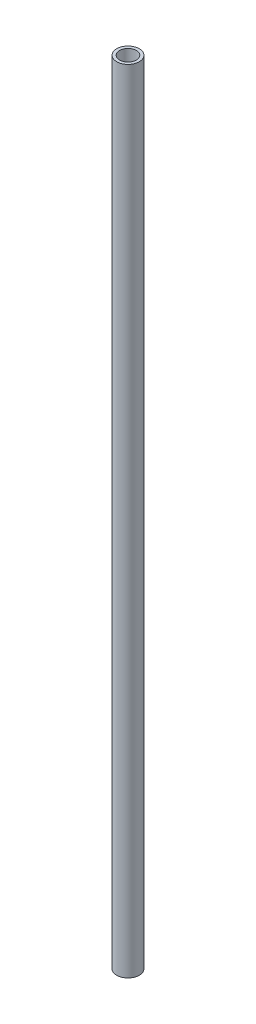
from build123d import *

# Parameters (mm, degrees)
SKETCH1_R           = 10.668
SKETCH1_R_2         = 7.8994
BOSS_EXTRUDE1_DEPTH = 748


with BuildPart() as part:
    # Sketch1 → Boss-Extrude1 (new body)
    with BuildSketch(Plane(origin=(0, 0, 0), x_dir=(1, 0, 0), z_dir=(0, 1, 0))):
        Circle(SKETCH1_R)
        Circle(SKETCH1_R_2, mode=Mode.SUBTRACT)
    extrude(amount=BOSS_EXTRUDE1_DEPTH)


solid = part.part
